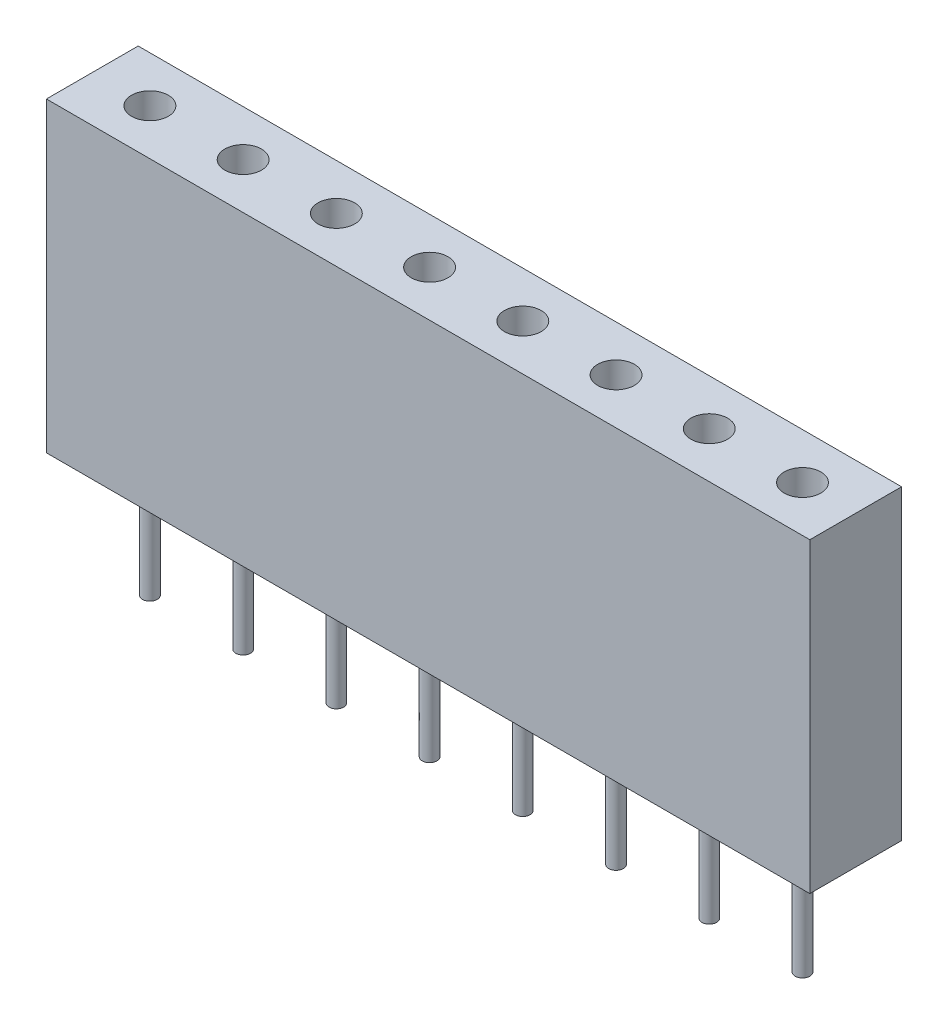
from build123d import *

# Parameters (mm, degrees)
SKETCH1_W           = 20.8
SKETCH1_H           = 2.5
BOSS_EXTRUDE1_DEPTH = 8.35
SKETCH2_R           = 0.5
CUT_EXTRUDE1_DEPTH  = 3
SKETCH3_R           = 0.2
BOSS_EXTRUDE2_DEPTH = 3.2
LPATTERN1_COUNT     = 8
LPATTERN1_PITCH     = 2.54


with BuildPart() as part:
    # Sketch1 → Boss-Extrude1 (new body)
    with BuildSketch(Plane(origin=(0, 0, 0), x_dir=(1, 0, 0), z_dir=(0, 1, 0))):
        Rectangle(SKETCH1_W, SKETCH1_H)
    extrude(amount=BOSS_EXTRUDE1_DEPTH)

    # Sketch2 → Cut-Extrude1 (cut)
    with BuildSketch(Plane(origin=(0, 8.35, 0), x_dir=(1, 0, 0), z_dir=(0, 1, 0))):
        with Locations((-8.83, 0)):
            Circle(SKETCH2_R)
    cut_extrude1 = extrude(amount=-CUT_EXTRUDE1_DEPTH, mode=Mode.SUBTRACT)

    # Sketch3 → Boss-Extrude2 (add)
    with BuildSketch(Plane.XZ):
        with Locations((-8.83, 0)):
            Circle(SKETCH3_R)
    boss_extrude2 = extrude(amount=BOSS_EXTRUDE2_DEPTH)

    # LPattern1: Cut-Extrude1, Boss-Extrude2 ×8
    with Locations(*[(i * LPATTERN1_PITCH, 0, 0) for i in range(1, LPATTERN1_COUNT)]):
        add(cut_extrude1, mode=Mode.SUBTRACT)
        add(boss_extrude2)


solid = part.part
